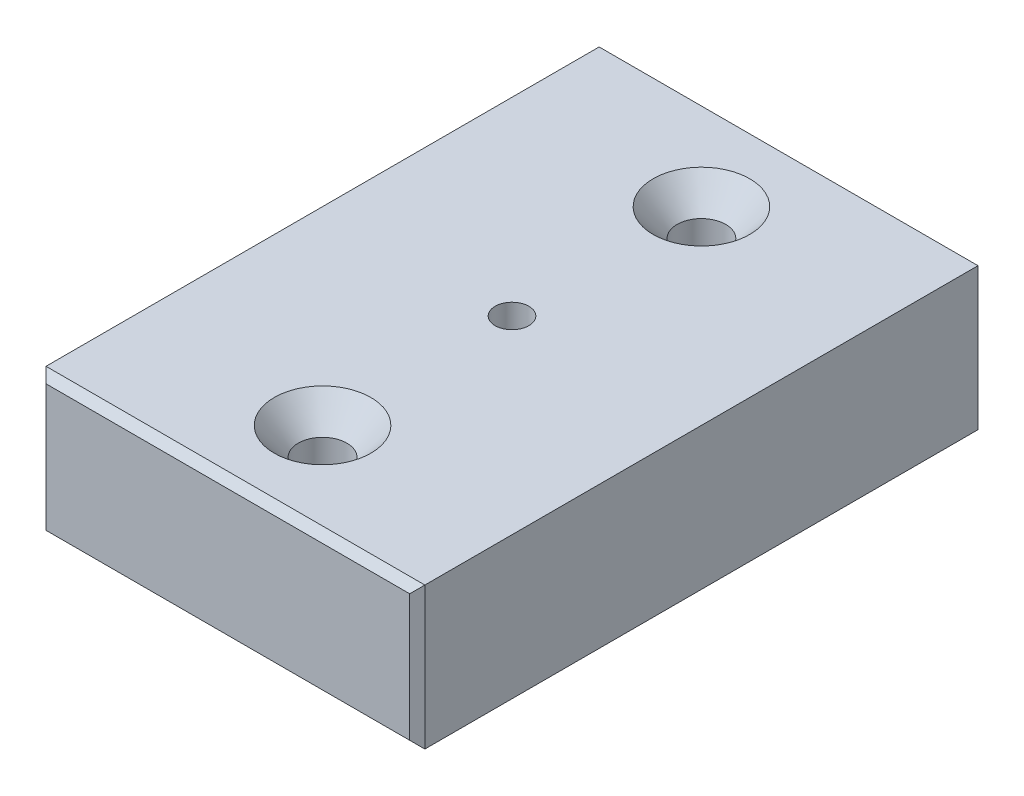
from build123d import *

# Parameters (mm, degrees)
SKETCH1_W                                         = 25.4
SKETCH1_H                                         = 9.525
BOSS_EXTRUDE1_DEPTH                               = 38.1
CSK_FOR_4_FLAT_HEAD_SOCKET_CAP_SCREW1_D           = 3.2639
CSK_FOR_4_FLAT_HEAD_SOCKET_CAP_SCREW1_DEPTH       = 9.525
CSK_FOR_4_FLAT_HEAD_SOCKET_CAP_SCREW1_CSINK_D     = 6.477
CSK_FOR_4_FLAT_HEAD_SOCKET_CAP_SCREW1_CSINK_ANGLE = 82
F_4_40_TAPPED_HOLE1_D                             = 2.2606
F_4_40_TAPPED_HOLE1_DEPTH                         = 9.525
CHAMFER1_SIZE                                     = 0.508


with BuildPart() as part:
    # Sketch1 → Boss-Extrude1 (new body)
    with BuildSketch(Plane.XY):
        Rectangle(SKETCH1_W, SKETCH1_H)
    extrude(amount=BOSS_EXTRUDE1_DEPTH)

    # CSK for #4 Flat Head Socket Cap Screw1
    with Locations(Plane(origin=(0, 4.7625, 0), x_dir=(1, 0, 0), z_dir=(0, 1, 0))):
        with Locations((0, -6.35), (0, -31.75)):
            CounterSinkHole(CSK_FOR_4_FLAT_HEAD_SOCKET_CAP_SCREW1_D / 2, CSK_FOR_4_FLAT_HEAD_SOCKET_CAP_SCREW1_CSINK_D / 2, depth=CSK_FOR_4_FLAT_HEAD_SOCKET_CAP_SCREW1_DEPTH, counter_sink_angle=CSK_FOR_4_FLAT_HEAD_SOCKET_CAP_SCREW1_CSINK_ANGLE)

    # #4-40 Tapped Hole1
    with Locations(Plane(origin=(0, 4.7625, 0), x_dir=(1, 0, 0), z_dir=(0, 1, 0))):
        with Locations((0, -19.05)):
            Hole(F_4_40_TAPPED_HOLE1_D / 2, depth=F_4_40_TAPPED_HOLE1_DEPTH)

    # Chamfer1
    chamfer1_edges = [part.edges().sort_by_distance(p)[0] for p in [
        (12.7, 0, 38.1),
        (0, 4.7625, 38.1),
        (-12.7, 0, 38.1),
        (0, 4.7625, 0),
        (12.7, 0, 0),
        (0, -4.7625, 0),
        (-12.7, 0, 0),
        (0, -4.7625, 38.1),
    ]]
    chamfer(chamfer1_edges, length=CHAMFER1_SIZE)


solid = part.part
